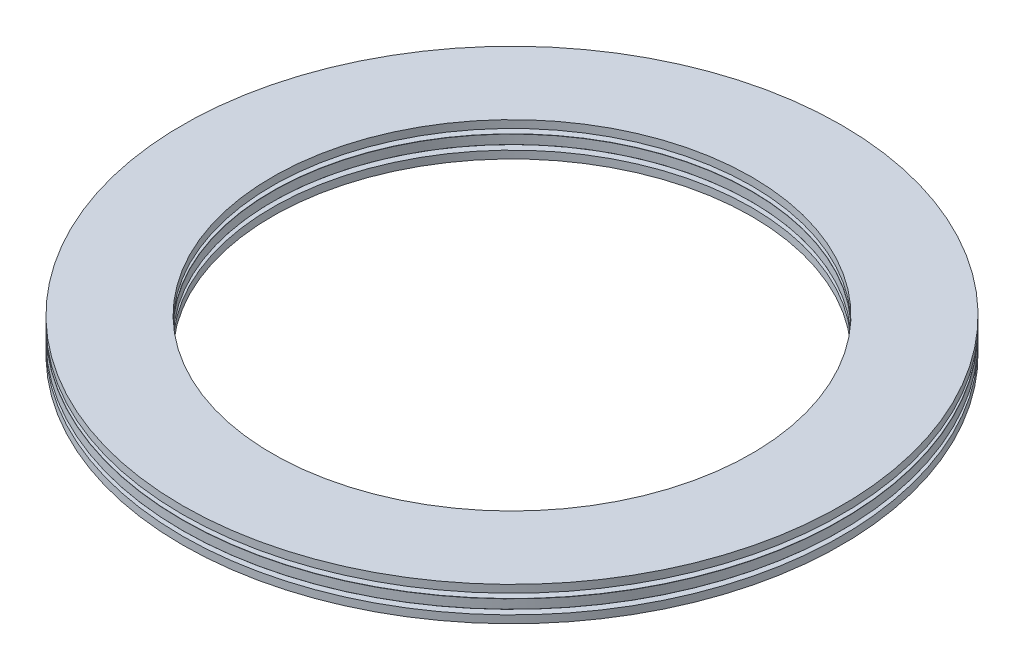
from build123d import *

# Parameters (mm, degrees)
SKETCH1_W         = 9.525
SKETCH1_H         = 0.9921875
SKETCH3_W         = 7.14375
SKETCH3_H         = 0.9921875
SKETCH2_W         = 7.14375
SKETCH2_H         = 0.9921875
CIRPATTERN1_COUNT = 55
CIRPATTERN2_COUNT = 55
SKETCH4_W         = 9.525
SKETCH4_H         = 0.8128
FILLET2_R         = 0.01984375


with BuildPart() as part:
    # Sketch1 → Revolve1 (revolve)
    with BuildSketch(Plane(origin=(0, 0, 0), x_dir=(0, 0, -1), z_dir=(1, 0, 0))):
        with Locations((-30.1625, 0)):
            Rectangle(SKETCH1_W, SKETCH1_H)
    revolve(axis=Axis((0, -0.9921875, 0), (0, 1, 0)))

    # Sketch3 → Cut-Revolve1 (revolve, cut)
    with BuildSketch(Plane(origin=(0, 0, 0), x_dir=(0, 0, -1), z_dir=(1, 0, 0))):
        with Locations((-30.1625, 0.49609375)):
            Rectangle(SKETCH3_W, SKETCH3_H)
    cut_revolve1 = revolve(axis=Axis((0, 0, 33.734375), (0, 0, -1)), mode=Mode.SUBTRACT)

    # CirPattern2: Cut-Revolve1 ×55 about axis
    cirpattern2_axis = Axis((0, 0.9921875, 0), (0, -1, 0))
    for i in range(1, CIRPATTERN2_COUNT):
        add(cut_revolve1.rotate(cirpattern2_axis, i * 360 / CIRPATTERN2_COUNT), mode=Mode.SUBTRACT)

    # Fillet2
    fillet2_edges = [part.edges().sort_by_distance(p)[0] for p in [
        (0, -0.49609375, -25.4),
        (0, 0.49609375, -25.4),
        (0, -0.49609375, -34.925),
        (0, 0.49609375, -34.925),
    ]]
    fillet(fillet2_edges, radius=FILLET2_R)


with BuildPart() as body_2:
    # Sketch2 → Revolve2 (revolve)
    with BuildSketch(Plane(origin=(0, 0, 0), x_dir=(0, 0, -1), z_dir=(1, 0, 0))):
        with Locations((-30.1625, 0.49609375)):
            Rectangle(SKETCH2_W, SKETCH2_H)
    revolve(axis=Axis((0, 0, 33.734375), (0, 0, -1)))


with BuildPart() as cirpattern1_1:
    # CirPattern1: pattern copy
    add(body_2.part.rotate(Axis((0, 0.9921875, 0), (0, -1, 0)), 1 * 360 / CIRPATTERN1_COUNT))


with BuildPart() as cirpattern1_2:
    # CirPattern1: pattern copy
    add(body_2.part.rotate(Axis((0, 0.9921875, 0), (0, -1, 0)), 2 * 360 / CIRPATTERN1_COUNT))


with BuildPart() as cirpattern1_3:
    # CirPattern1: pattern copy
    add(body_2.part.rotate(Axis((0, 0.9921875, 0), (0, -1, 0)), 3 * 360 / CIRPATTERN1_COUNT))


with BuildPart() as cirpattern1_4:
    # CirPattern1: pattern copy
    add(body_2.part.rotate(Axis((0, 0.9921875, 0), (0, -1, 0)), 4 * 360 / CIRPATTERN1_COUNT))


with BuildPart() as cirpattern1_5:
    # CirPattern1: pattern copy
    add(body_2.part.rotate(Axis((0, 0.9921875, 0), (0, -1, 0)), 5 * 360 / CIRPATTERN1_COUNT))


with BuildPart() as cirpattern1_6:
    # CirPattern1: pattern copy
    add(body_2.part.rotate(Axis((0, 0.9921875, 0), (0, -1, 0)), 6 * 360 / CIRPATTERN1_COUNT))


with BuildPart() as cirpattern1_7:
    # CirPattern1: pattern copy
    add(body_2.part.rotate(Axis((0, 0.9921875, 0), (0, -1, 0)), 7 * 360 / CIRPATTERN1_COUNT))


with BuildPart() as cirpattern1_8:
    # CirPattern1: pattern copy
    add(body_2.part.rotate(Axis((0, 0.9921875, 0), (0, -1, 0)), 8 * 360 / CIRPATTERN1_COUNT))


with BuildPart() as cirpattern1_9:
    # CirPattern1: pattern copy
    add(body_2.part.rotate(Axis((0, 0.9921875, 0), (0, -1, 0)), 9 * 360 / CIRPATTERN1_COUNT))


with BuildPart() as cirpattern1_10:
    # CirPattern1: pattern copy
    add(body_2.part.rotate(Axis((0, 0.9921875, 0), (0, -1, 0)), 10 * 360 / CIRPATTERN1_COUNT))


with BuildPart() as cirpattern1_11:
    # CirPattern1: pattern copy
    add(body_2.part.rotate(Axis((0, 0.9921875, 0), (0, -1, 0)), 11 * 360 / CIRPATTERN1_COUNT))


with BuildPart() as cirpattern1_12:
    # CirPattern1: pattern copy
    add(body_2.part.rotate(Axis((0, 0.9921875, 0), (0, -1, 0)), 12 * 360 / CIRPATTERN1_COUNT))


with BuildPart() as cirpattern1_13:
    # CirPattern1: pattern copy
    add(body_2.part.rotate(Axis((0, 0.9921875, 0), (0, -1, 0)), 13 * 360 / CIRPATTERN1_COUNT))


with BuildPart() as cirpattern1_14:
    # CirPattern1: pattern copy
    add(body_2.part.rotate(Axis((0, 0.9921875, 0), (0, -1, 0)), 14 * 360 / CIRPATTERN1_COUNT))


with BuildPart() as cirpattern1_15:
    # CirPattern1: pattern copy
    add(body_2.part.rotate(Axis((0, 0.9921875, 0), (0, -1, 0)), 15 * 360 / CIRPATTERN1_COUNT))


with BuildPart() as cirpattern1_16:
    # CirPattern1: pattern copy
    add(body_2.part.rotate(Axis((0, 0.9921875, 0), (0, -1, 0)), 16 * 360 / CIRPATTERN1_COUNT))


with BuildPart() as cirpattern1_17:
    # CirPattern1: pattern copy
    add(body_2.part.rotate(Axis((0, 0.9921875, 0), (0, -1, 0)), 17 * 360 / CIRPATTERN1_COUNT))


with BuildPart() as cirpattern1_18:
    # CirPattern1: pattern copy
    add(body_2.part.rotate(Axis((0, 0.9921875, 0), (0, -1, 0)), 18 * 360 / CIRPATTERN1_COUNT))


with BuildPart() as cirpattern1_19:
    # CirPattern1: pattern copy
    add(body_2.part.rotate(Axis((0, 0.9921875, 0), (0, -1, 0)), 19 * 360 / CIRPATTERN1_COUNT))


with BuildPart() as cirpattern1_20:
    # CirPattern1: pattern copy
    add(body_2.part.rotate(Axis((0, 0.9921875, 0), (0, -1, 0)), 20 * 360 / CIRPATTERN1_COUNT))


with BuildPart() as cirpattern1_21:
    # CirPattern1: pattern copy
    add(body_2.part.rotate(Axis((0, 0.9921875, 0), (0, -1, 0)), 21 * 360 / CIRPATTERN1_COUNT))


with BuildPart() as cirpattern1_22:
    # CirPattern1: pattern copy
    add(body_2.part.rotate(Axis((0, 0.9921875, 0), (0, -1, 0)), 22 * 360 / CIRPATTERN1_COUNT))


with BuildPart() as cirpattern1_23:
    # CirPattern1: pattern copy
    add(body_2.part.rotate(Axis((0, 0.9921875, 0), (0, -1, 0)), 23 * 360 / CIRPATTERN1_COUNT))


with BuildPart() as cirpattern1_24:
    # CirPattern1: pattern copy
    add(body_2.part.rotate(Axis((0, 0.9921875, 0), (0, -1, 0)), 24 * 360 / CIRPATTERN1_COUNT))


with BuildPart() as cirpattern1_25:
    # CirPattern1: pattern copy
    add(body_2.part.rotate(Axis((0, 0.9921875, 0), (0, -1, 0)), 25 * 360 / CIRPATTERN1_COUNT))


with BuildPart() as cirpattern1_26:
    # CirPattern1: pattern copy
    add(body_2.part.rotate(Axis((0, 0.9921875, 0), (0, -1, 0)), 26 * 360 / CIRPATTERN1_COUNT))


with BuildPart() as cirpattern1_27:
    # CirPattern1: pattern copy
    add(body_2.part.rotate(Axis((0, 0.9921875, 0), (0, -1, 0)), 27 * 360 / CIRPATTERN1_COUNT))


with BuildPart() as cirpattern1_28:
    # CirPattern1: pattern copy
    add(body_2.part.rotate(Axis((0, 0.9921875, 0), (0, -1, 0)), 28 * 360 / CIRPATTERN1_COUNT))


with BuildPart() as cirpattern1_29:
    # CirPattern1: pattern copy
    add(body_2.part.rotate(Axis((0, 0.9921875, 0), (0, -1, 0)), 29 * 360 / CIRPATTERN1_COUNT))


with BuildPart() as cirpattern1_30:
    # CirPattern1: pattern copy
    add(body_2.part.rotate(Axis((0, 0.9921875, 0), (0, -1, 0)), 30 * 360 / CIRPATTERN1_COUNT))


with BuildPart() as cirpattern1_31:
    # CirPattern1: pattern copy
    add(body_2.part.rotate(Axis((0, 0.9921875, 0), (0, -1, 0)), 31 * 360 / CIRPATTERN1_COUNT))


with BuildPart() as cirpattern1_32:
    # CirPattern1: pattern copy
    add(body_2.part.rotate(Axis((0, 0.9921875, 0), (0, -1, 0)), 32 * 360 / CIRPATTERN1_COUNT))


with BuildPart() as cirpattern1_33:
    # CirPattern1: pattern copy
    add(body_2.part.rotate(Axis((0, 0.9921875, 0), (0, -1, 0)), 33 * 360 / CIRPATTERN1_COUNT))


with BuildPart() as cirpattern1_34:
    # CirPattern1: pattern copy
    add(body_2.part.rotate(Axis((0, 0.9921875, 0), (0, -1, 0)), 34 * 360 / CIRPATTERN1_COUNT))


with BuildPart() as cirpattern1_35:
    # CirPattern1: pattern copy
    add(body_2.part.rotate(Axis((0, 0.9921875, 0), (0, -1, 0)), 35 * 360 / CIRPATTERN1_COUNT))


with BuildPart() as cirpattern1_36:
    # CirPattern1: pattern copy
    add(body_2.part.rotate(Axis((0, 0.9921875, 0), (0, -1, 0)), 36 * 360 / CIRPATTERN1_COUNT))


with BuildPart() as cirpattern1_37:
    # CirPattern1: pattern copy
    add(body_2.part.rotate(Axis((0, 0.9921875, 0), (0, -1, 0)), 37 * 360 / CIRPATTERN1_COUNT))


with BuildPart() as cirpattern1_38:
    # CirPattern1: pattern copy
    add(body_2.part.rotate(Axis((0, 0.9921875, 0), (0, -1, 0)), 38 * 360 / CIRPATTERN1_COUNT))


with BuildPart() as cirpattern1_39:
    # CirPattern1: pattern copy
    add(body_2.part.rotate(Axis((0, 0.9921875, 0), (0, -1, 0)), 39 * 360 / CIRPATTERN1_COUNT))


with BuildPart() as cirpattern1_40:
    # CirPattern1: pattern copy
    add(body_2.part.rotate(Axis((0, 0.9921875, 0), (0, -1, 0)), 40 * 360 / CIRPATTERN1_COUNT))


with BuildPart() as cirpattern1_41:
    # CirPattern1: pattern copy
    add(body_2.part.rotate(Axis((0, 0.9921875, 0), (0, -1, 0)), 41 * 360 / CIRPATTERN1_COUNT))


with BuildPart() as cirpattern1_42:
    # CirPattern1: pattern copy
    add(body_2.part.rotate(Axis((0, 0.9921875, 0), (0, -1, 0)), 42 * 360 / CIRPATTERN1_COUNT))


with BuildPart() as cirpattern1_43:
    # CirPattern1: pattern copy
    add(body_2.part.rotate(Axis((0, 0.9921875, 0), (0, -1, 0)), 43 * 360 / CIRPATTERN1_COUNT))


with BuildPart() as cirpattern1_44:
    # CirPattern1: pattern copy
    add(body_2.part.rotate(Axis((0, 0.9921875, 0), (0, -1, 0)), 44 * 360 / CIRPATTERN1_COUNT))


with BuildPart() as cirpattern1_45:
    # CirPattern1: pattern copy
    add(body_2.part.rotate(Axis((0, 0.9921875, 0), (0, -1, 0)), 45 * 360 / CIRPATTERN1_COUNT))


with BuildPart() as cirpattern1_46:
    # CirPattern1: pattern copy
    add(body_2.part.rotate(Axis((0, 0.9921875, 0), (0, -1, 0)), 46 * 360 / CIRPATTERN1_COUNT))


with BuildPart() as cirpattern1_47:
    # CirPattern1: pattern copy
    add(body_2.part.rotate(Axis((0, 0.9921875, 0), (0, -1, 0)), 47 * 360 / CIRPATTERN1_COUNT))


with BuildPart() as cirpattern1_48:
    # CirPattern1: pattern copy
    add(body_2.part.rotate(Axis((0, 0.9921875, 0), (0, -1, 0)), 48 * 360 / CIRPATTERN1_COUNT))


with BuildPart() as cirpattern1_49:
    # CirPattern1: pattern copy
    add(body_2.part.rotate(Axis((0, 0.9921875, 0), (0, -1, 0)), 49 * 360 / CIRPATTERN1_COUNT))


with BuildPart() as cirpattern1_50:
    # CirPattern1: pattern copy
    add(body_2.part.rotate(Axis((0, 0.9921875, 0), (0, -1, 0)), 50 * 360 / CIRPATTERN1_COUNT))


with BuildPart() as cirpattern1_51:
    # CirPattern1: pattern copy
    add(body_2.part.rotate(Axis((0, 0.9921875, 0), (0, -1, 0)), 51 * 360 / CIRPATTERN1_COUNT))


with BuildPart() as cirpattern1_52:
    # CirPattern1: pattern copy
    add(body_2.part.rotate(Axis((0, 0.9921875, 0), (0, -1, 0)), 52 * 360 / CIRPATTERN1_COUNT))


with BuildPart() as cirpattern1_53:
    # CirPattern1: pattern copy
    add(body_2.part.rotate(Axis((0, 0.9921875, 0), (0, -1, 0)), 53 * 360 / CIRPATTERN1_COUNT))


with BuildPart() as cirpattern1_54:
    # CirPattern1: pattern copy
    add(body_2.part.rotate(Axis((0, 0.9921875, 0), (0, -1, 0)), 54 * 360 / CIRPATTERN1_COUNT))


with BuildPart() as body_57:
    # Sketch4 → Revolve3 (revolve)
    with BuildSketch(Plane(origin=(0, 0, 0), x_dir=(0, 0, -1), z_dir=(1, 0, 0))):
        with Locations((-30.1625, 1.39954)):
            Rectangle(SKETCH4_W, SKETCH4_H)
        with Locations((-30.1625, -1.39954)):
            Rectangle(SKETCH4_W, SKETCH4_H)
    revolve(axis=Axis((0, -0.9921875, 0), (0, 1, 0)))


solid = Compound([part.part, body_2.part, cirpattern1_1.part, cirpattern1_2.part, cirpattern1_3.part, cirpattern1_4.part, cirpattern1_5.part, cirpattern1_6.part, cirpattern1_7.part, cirpattern1_8.part, cirpattern1_9.part, cirpattern1_10.part, cirpattern1_11.part, cirpattern1_12.part, cirpattern1_13.part, cirpattern1_14.part, cirpattern1_15.part, cirpattern1_16.part, cirpattern1_17.part, cirpattern1_18.part, cirpattern1_19.part, cirpattern1_20.part, cirpattern1_21.part, cirpattern1_22.part, cirpattern1_23.part, cirpattern1_24.part, cirpattern1_25.part, cirpattern1_26.part, cirpattern1_27.part, cirpattern1_28.part, cirpattern1_29.part, cirpattern1_30.part, cirpattern1_31.part, cirpattern1_32.part, cirpattern1_33.part, cirpattern1_34.part, cirpattern1_35.part, cirpattern1_36.part, cirpattern1_37.part, cirpattern1_38.part, cirpattern1_39.part, cirpattern1_40.part, cirpattern1_41.part, cirpattern1_42.part, cirpattern1_43.part, cirpattern1_44.part, cirpattern1_45.part, cirpattern1_46.part, cirpattern1_47.part, cirpattern1_48.part, cirpattern1_49.part, cirpattern1_50.part, cirpattern1_51.part, cirpattern1_52.part, cirpattern1_53.part, cirpattern1_54.part, body_57.part])
